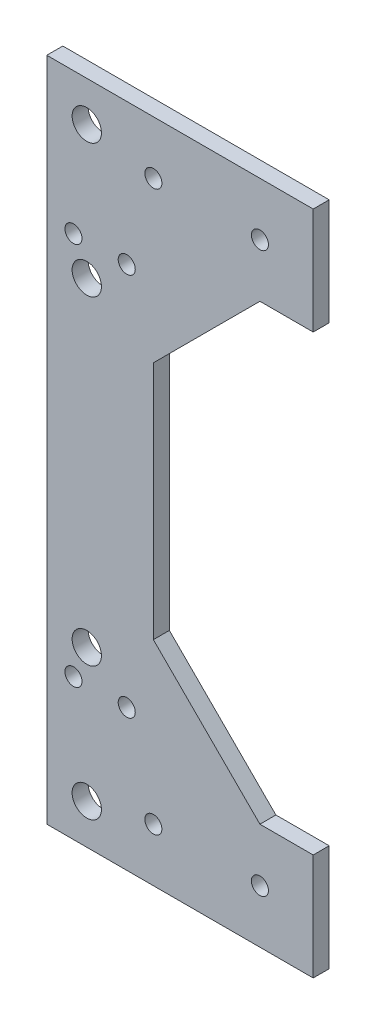
from build123d import *

# Parameters (mm, degrees)
SKETCH1_R          = 1.6
EXTRUDE1_DEPTH     = 3
SKETCH2_R          = 1.6
CUT_EXTRUDE1_DEPTH = 26
SKETCH3_R          = 2.75
CUT_EXTRUDE2_DEPTH = 10


with BuildPart() as part:
    # Sketch1 → Extrude1 (new body)
    with BuildSketch(Plane.XY):
        Polygon((-95, 62.5), (-95, -62.5), (-55, -62.5), (-45, -62.5), (-45, -42.5), (-55, -42.5), (-75, -22.5), (-75, 22.5), (-55, 42.5), (-45, 42.5), (-45, 62.5), (-55, 62.5), align=None)
        with Locations((-55, -52.5)):
            Circle(SKETCH1_R, mode=Mode.SUBTRACT)
        with Locations((-75, -52.5)):
            Circle(SKETCH1_R, mode=Mode.SUBTRACT)
        with Locations((-55, 52.5)):
            Circle(SKETCH1_R, mode=Mode.SUBTRACT)
        with Locations((-75, 52.5)):
            Circle(SKETCH1_R, mode=Mode.SUBTRACT)
    extrude(amount=EXTRUDE1_DEPTH)

    # Sketch2 → Cut-Extrude1 (cut)
    with BuildSketch(Plane.XY.offset(3)):
        with Locations((-80, 36)):
            Circle(SKETCH2_R)
        with Locations((-90, 36)):
            Circle(SKETCH2_R)
        with Locations((-80, -36)):
            Circle(SKETCH2_R)
        with Locations((-90, -36)):
            Circle(SKETCH2_R)
    extrude(amount=-CUT_EXTRUDE1_DEPTH, mode=Mode.SUBTRACT)

    # Sketch3 → Cut-Extrude2 (cut)
    with BuildSketch(Plane(origin=(0, 0, 0), x_dir=(-1, 0, 0), z_dir=(0, 0, -1))):
        with Locations((87.5, 55)):
            Circle(SKETCH3_R)
        with Locations((87.5, 30)):
            Circle(SKETCH3_R)
        with Locations((87.5, -30)):
            Circle(SKETCH3_R)
        with Locations((87.5, -55)):
            Circle(SKETCH3_R)
    extrude(amount=-CUT_EXTRUDE2_DEPTH, mode=Mode.SUBTRACT)


solid = part.part
